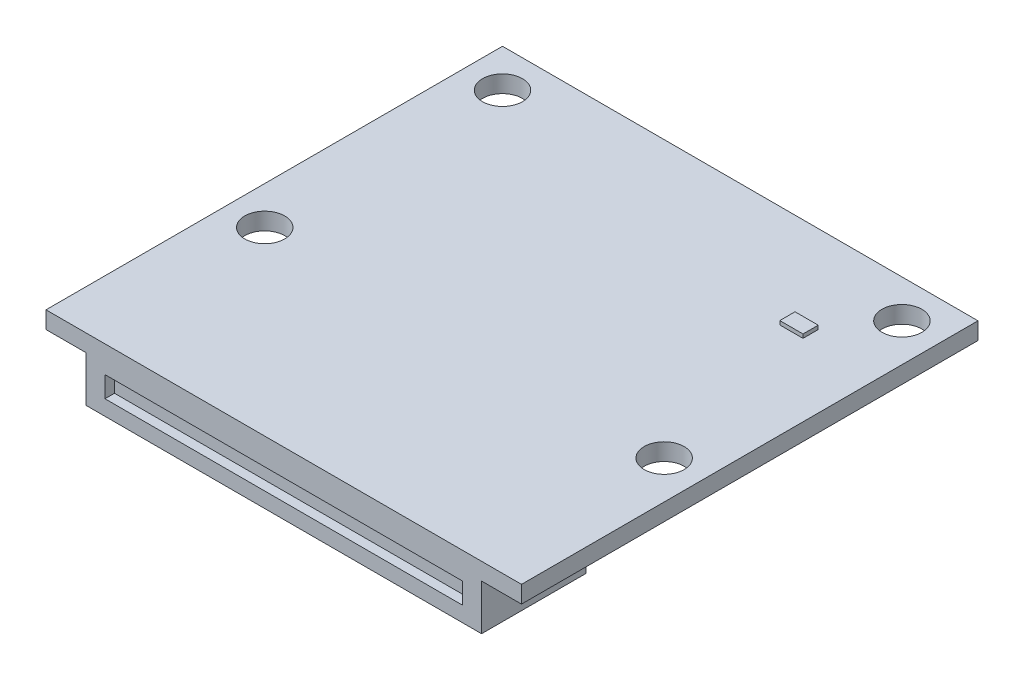
from build123d import *

# Parameters (mm, degrees)
SKIZZE1_W               = 25
SKIZZE1_H               = 24
PCB_DEPTH               = 0.9
SKIZZE2_R               = 1.05
MOUNTING_HOLES_DEPTH    = 1.9
SKIZZE3_W               = 20.8
SKIZZE3_H               = 5.5
CONNECTOR_CLOSED_DEPTH  = 2.4
ESQUISSE1_W             = 1.22
ESQUISSE1_H             = 0.8
STATUS_LED_DEPTH        = 0.2
ESQUISSE3_W             = 18.8
ESQUISSE3_H             = 1.1
ENL_V_MAT_EXTRU_1_DEPTH = 0.5


with BuildPart() as part:
    # Skizze1 → PCB (new body)
    with BuildSketch(Plane(origin=(0, 0, 0), x_dir=(1, 0, 0), z_dir=(0, 1, 0))):
        with Locations((0, 2.5)):
            Rectangle(SKIZZE1_W, SKIZZE1_H)
    extrude(amount=-PCB_DEPTH)

    # Skizze2 → Mounting_Holes (cut, through all)
    with BuildSketch(Plane(origin=(0, 0, 0), x_dir=(1, 0, 0), z_dir=(0, 1, 0))):
        with Locations(Location((10.5, 12.5, 0), (0, 0, 270))):  # turned: the seam where the file's is
            Circle(SKIZZE2_R)
        with Locations(Location((10.5, 0, 0), (0, 0, 270))):  # turned: the seam where the file's is
            Circle(SKIZZE2_R)
        with Locations(Location((-10.5, 0, 0), (0, 0, 90))):  # turned: the seam where the file's is
            Circle(SKIZZE2_R)
        with Locations(Location((-10.5, 12.5, 0), (0, 0, 90))):  # turned: the seam where the file's is
            Circle(SKIZZE2_R)
    extrude(amount=-MOUNTING_HOLES_DEPTH, mode=Mode.SUBTRACT)

    # Skizze3 → Connector_closed (add)
    with BuildSketch(Plane.XZ.offset(0.9)):
        with Locations((0, 6.75)):
            Rectangle(SKIZZE3_W, SKIZZE3_H)
    extrude(amount=CONNECTOR_CLOSED_DEPTH)

    # Esquisse1 → Status LED (add)
    with BuildSketch(Plane(origin=(0, 0, 0), x_dir=(1, 0, 0), z_dir=(0, 1, 0))):
        with Locations((8.09, 9.5)):
            Rectangle(ESQUISSE1_W, ESQUISSE1_H)
    extrude(amount=STATUS_LED_DEPTH)

    # Esquisse3 → Enlèv. mat.-Extru.1 (cut)
    with BuildSketch(Plane.XY.offset(9.5)):
        with Locations((0, -1.95)):
            Rectangle(ESQUISSE3_W, ESQUISSE3_H)
    extrude(amount=-ENL_V_MAT_EXTRU_1_DEPTH, mode=Mode.SUBTRACT)


solid = part.part
